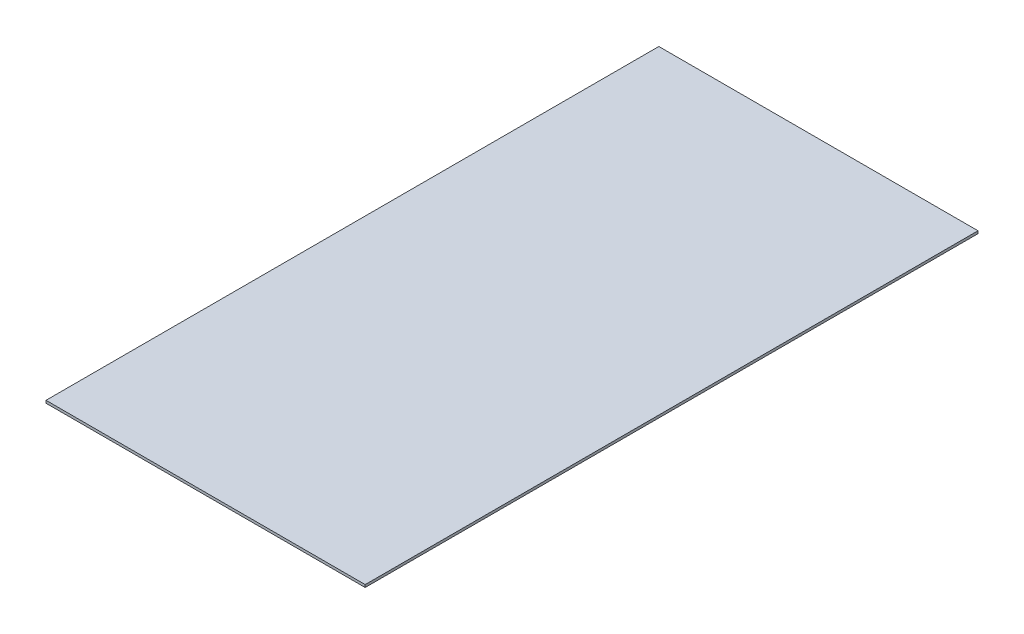
from build123d import *

# Parameters (mm, degrees)
SKETCH1_W           = 317.5
SKETCH1_H           = 609.6
BOSS_EXTRUDE1_DEPTH = 2.54


with BuildPart() as part:
    # Sketch1 → Boss-Extrude1 (new body)
    with BuildSketch(Plane(origin=(0, 0, 0), x_dir=(1, 0, 0), z_dir=(0, 1, 0))):
        with Locations((158.75, 304.8)):
            Rectangle(SKETCH1_W, SKETCH1_H)
    extrude(amount=BOSS_EXTRUDE1_DEPTH)


solid = part.part
